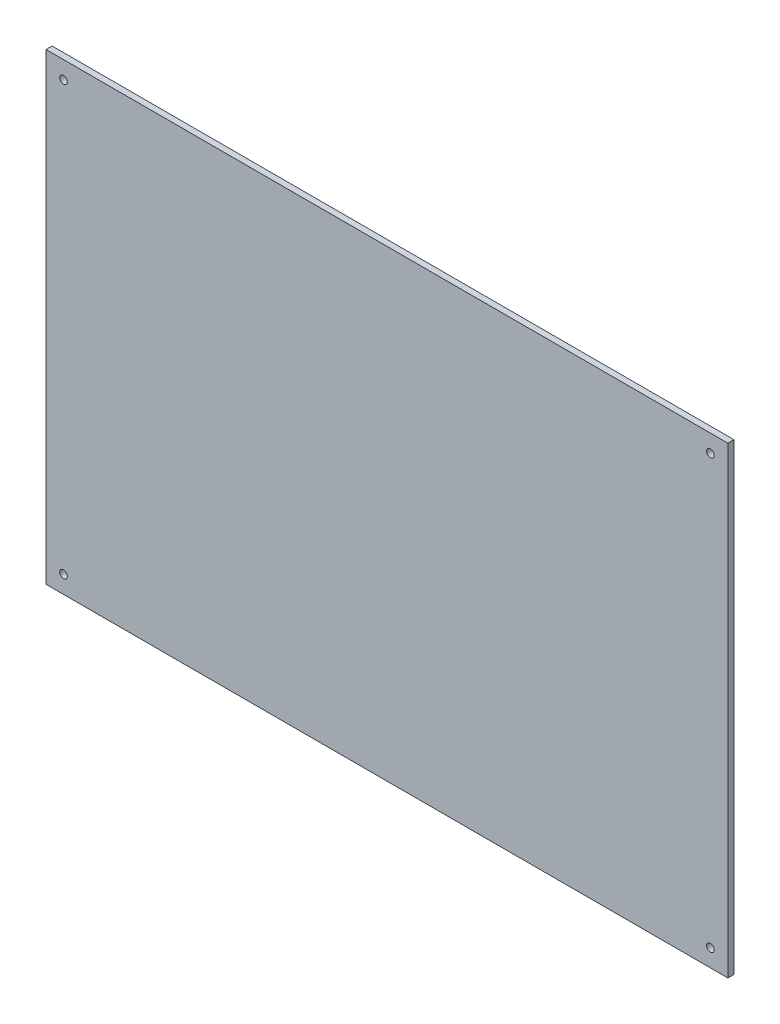
from build123d import *

# Parameters (mm, degrees)
SCHIZZO1_W                   = 449
SCHIZZO1_H                   = 305
SCHIZZO1_R                   = 2.5
ESTRUSIONE_ESTRUSIONE1_DEPTH = 4


with BuildPart() as part:
    # Schizzo1 → Estrusione-Estrusione1 (new body)
    with BuildSketch(Plane.XY):
        with Locations((-224.5, 152.5)):
            Rectangle(SCHIZZO1_W, SCHIZZO1_H)
        with Locations((-437.5, 293.5)):
            Circle(SCHIZZO1_R, mode=Mode.SUBTRACT)
        with Locations((-11.5, 293.5)):
            Circle(SCHIZZO1_R, mode=Mode.SUBTRACT)
        with Locations((-437.5, 11.5)):
            Circle(SCHIZZO1_R, mode=Mode.SUBTRACT)
        with Locations((-11.5, 11.5)):
            Circle(SCHIZZO1_R, mode=Mode.SUBTRACT)
    extrude(amount=ESTRUSIONE_ESTRUSIONE1_DEPTH)


solid = part.part
